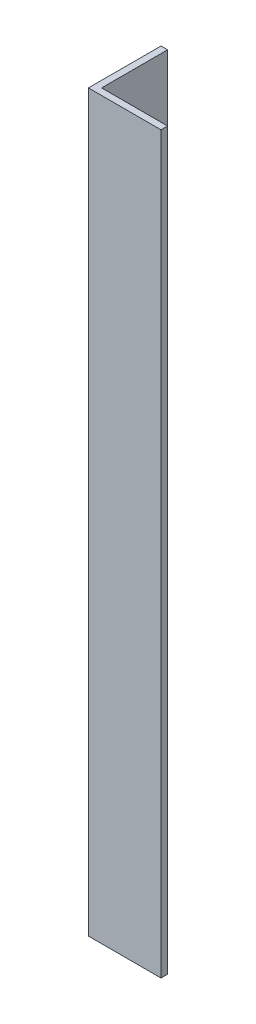
from build123d import *

# Parameters (mm, degrees)
EXTRUDE_1_DEPTH = 334


with BuildPart() as part:
    # Эскиз1 → Вытянуть-Тонкостенный1 (new body)
    with BuildSketch(Plane(origin=(0, 0, 0), x_dir=(1, 0, 0), z_dir=(0, 1, 0))):
        Polygon((0, 33), (0, 0), (33, 0), (33, 3), (3, 3), (3, 33), align=None)
    extrude(amount=EXTRUDE_1_DEPTH)


solid = part.part
